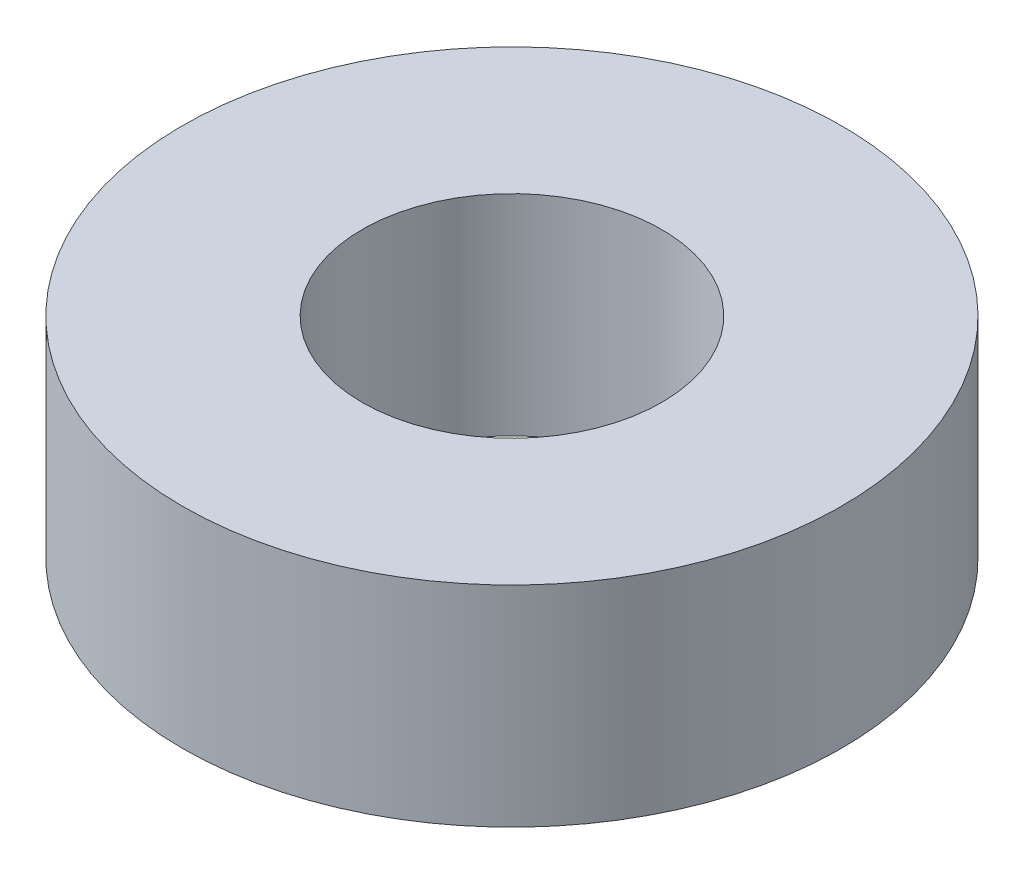
from build123d import *

# Parameters (mm, degrees)
SKETCH2_R           = 11
SKETCH2_R_2         = 5
BOSS_EXTRUDE1_DEPTH = 7


with BuildPart() as part:
    # Sketch2 → Boss-Extrude1 (new body)
    with BuildSketch(Plane(origin=(0, 0, 0), x_dir=(1, 0, 0), z_dir=(0, 1, 0))):
        Circle(SKETCH2_R)
        Circle(SKETCH2_R_2, mode=Mode.SUBTRACT)
    extrude(amount=BOSS_EXTRUDE1_DEPTH)


solid = part.part
